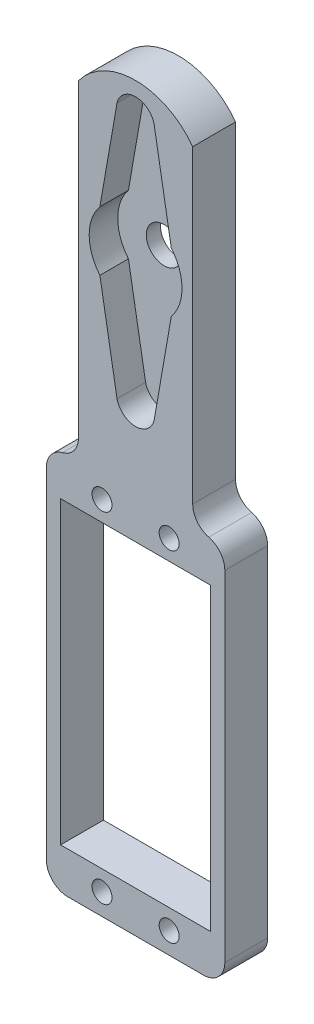
from build123d import *

# Parameters (mm, degrees)
SKETCH_1_R      = 1.4
SKETCH_1_W      = 21
SKETCH_1_H      = 42
EXTRUDE_1_DEPTH = 6
FILLET_6_R      = 3
FILLET_7_R      = 3
FILLET_8_R      = 3
FILLET_9_R      = 3
FILLET_10_R     = 3
FILLET_11_R     = 3
SKETCH_2_R      = 2.5
EXTRUDE_2_DEPTH = 2


with BuildPart() as part:
    # 草圖1 → 填料-伸長1 (new body)
    with BuildSketch(Plane.XY):
        with BuildLine():
            Line((8, -18.141285654), (8, 17.94275172))
            ThreePointArc((8, 17.94275172), (0, 21.985231559), (-8, 17.94275172))
            Line((-8, 17.94275172), (-8, -18.141285654))
            Line((-8, -18.141285654), (-8, -28.206652459))
            Line((-8, -28.206652459), (-12.5, -28.206652459))
            Line((-12.5, -28.206652459), (-12.5, -81.793347541))
            Line((-12.5, -81.793347541), (12.5, -81.793347541))
            Line((12.5, -81.793347541), (12.5, -28.206652459))
            Line((12.5, -28.206652459), (8, -28.206652459))
            Line((8, -28.206652459), (8, -18.141285654))
        make_face()
        with Locations((-4.7, -78.8)):
            Circle(SKETCH_1_R, mode=Mode.SUBTRACT)
        with Locations((0, -55)):
            Rectangle(SKETCH_1_W, SKETCH_1_H, mode=Mode.SUBTRACT)
        with Locations((-4.7, -31.2)):
            Circle(SKETCH_1_R, mode=Mode.SUBTRACT)
        with Locations((4.7, -78.8)):
            Circle(SKETCH_1_R, mode=Mode.SUBTRACT)
        with Locations((4.7, -31.2)):
            Circle(SKETCH_1_R, mode=Mode.SUBTRACT)
        with BuildLine():
            ThreePointArc((-4.999271035, -4.154189345), (-6.5, 0), (-4.999271035, 4.154189345))
            Line((-4.999271035, 4.154189345), (-2.6, 17.94275172))
            ThreePointArc((-2.6, 17.94275172), (0, 20), (2.6, 17.94275172))
            Line((2.6, 17.94275172), (4.999271035, 4.154189345))
            ThreePointArc((4.999271035, 4.154189345), (6.5, 0), (4.999271035, -4.154189345))
            Line((4.999271035, -4.154189345), (2.6, -17.94275172))
            ThreePointArc((2.6, -17.94275172), (0, -20), (-2.6, -17.94275172))
            Line((-2.6, -17.94275172), (-4.999271035, -4.154189345))
        make_face(mode=Mode.SUBTRACT)
    extrude(amount=EXTRUDE_1_DEPTH)

    # 圓角6
    fillet_6_edges = [part.edges().sort_by_distance(p)[0] for p in [
        (-12.5, -81.793347541, 3),
    ]]
    fillet(fillet_6_edges, radius=FILLET_6_R)

    # 圓角7
    fillet_7_edges = [part.edges().sort_by_distance(p)[0] for p in [
        (12.5, -81.793347541, 3),
    ]]
    fillet(fillet_7_edges, radius=FILLET_7_R)

    # 圓角8
    fillet_8_edges = [part.edges().sort_by_distance(p)[0] for p in [
        (12.5, -28.206652459, 3),
    ]]
    fillet(fillet_8_edges, radius=FILLET_8_R)

    # 圓角9
    fillet_9_edges = [part.edges().sort_by_distance(p)[0] for p in [
        (8, -28.206652459, 3),
    ]]
    fillet(fillet_9_edges, radius=FILLET_9_R)

    # 圓角10
    fillet_10_edges = [part.edges().sort_by_distance(p)[0] for p in [
        (-12.5, -28.206652459, 3),
    ]]
    fillet(fillet_10_edges, radius=FILLET_10_R)

    # 圓角11
    fillet_11_edges = [part.edges().sort_by_distance(p)[0] for p in [
        (-8, -28.206652459, 3),
    ]]
    fillet(fillet_11_edges, radius=FILLET_11_R)

    # 草圖2 → 填料-伸長2 (add)
    with BuildSketch(Plane.XY):
        with BuildLine():
            Line((-3.702325647, 20.172267208), (4.497563026, 20.172267208))
            ThreePointArc((4.497563026, 20.172267208), (6.068658829, 19.068237677), (7.032818959, 17.407629814))
            Line((7.032818959, 17.407629814), (7.032818959, -20.628324178))
            Line((7.032818959, -20.628324178), (-6.646673958, -20.628324178))
            Line((-6.646673958, -20.628324178), (-6.646673958, 17.471058727))
            ThreePointArc((-6.646673958, 17.471058727), (-5.621736824, 19.309156464), (-3.702325647, 20.172267208))
        make_face()
        Circle(SKETCH_2_R, mode=Mode.SUBTRACT)
    extrude(amount=EXTRUDE_2_DEPTH)


solid = part.part
